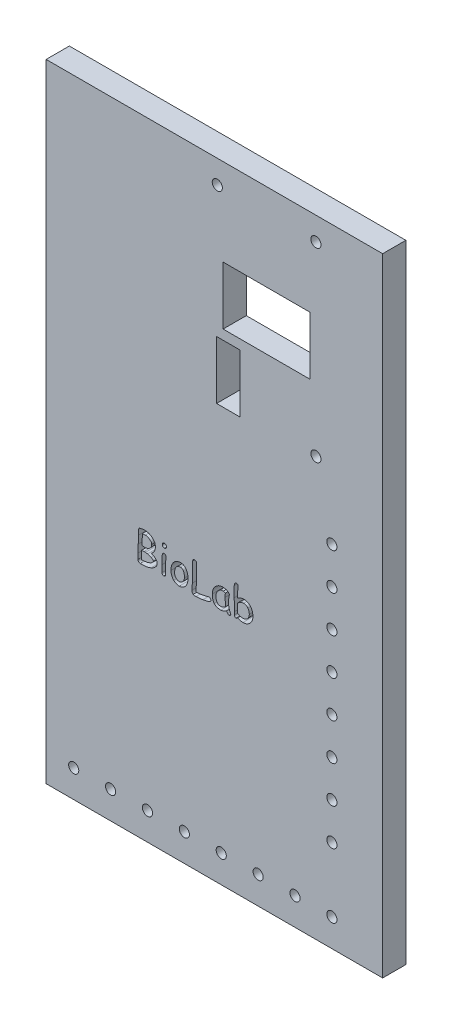
from build123d import *

# Parameters (mm, degrees)
ESBO_O1_W                = 116
ESBO_O1_H                = 216.23
ESBO_O1_R                = 1.75
ESBO_O1_W_2              = 8
ESBO_O1_H_2              = 20
ESBO_O1_W_3              = 30
RESSALTO_EXTRUS_O1_DEPTH = 8
ESBO_O2_R                = 1.75
CORTE_EXTRUS_O1_DEPTH    = 100
PADR_O_LINEAR1_COUNT     = 8
PADR_O_LINEAR1_PITCH     = 12.714285714
ESBO_O3_R                = 1.75
CORTE_EXTRUS_O2_DEPTH    = 100
PADR_O_LINEAR2_COUNT     = 8
PADR_O_LINEAR2_PITCH     = 12.714285714
CORTE_EXTRUS_O3_DEPTH    = 10


with BuildPart() as part:
    # Esboço1 → Ressalto-extrusão1 (new body)
    with BuildSketch(Plane.XY):
        Rectangle(ESBO_O1_W, ESBO_O1_H)
        with Locations((35, 100.115)):
            Circle(ESBO_O1_R, mode=Mode.SUBTRACT)
        with Locations((35, 36.115)):
            Circle(ESBO_O1_R, mode=Mode.SUBTRACT)
        with Locations((1, 100.115)):
            Circle(ESBO_O1_R, mode=Mode.SUBTRACT)
        with Locations((4.75, 44.775)):
            Rectangle(ESBO_O1_W_2, ESBO_O1_H_2, mode=Mode.SUBTRACT)
        with Locations((18, 68.115)):
            Rectangle(ESBO_O1_W_3, ESBO_O1_H_2, mode=Mode.SUBTRACT)
    extrude(amount=RESSALTO_EXTRUS_O1_DEPTH)

    # Esboço2 → Corte-extrusão1 (cut)
    with BuildSketch(Plane.XY.offset(8)):
        with Locations((-48.5, -98.615)):
            Circle(ESBO_O2_R)
    corte_extrus_o1 = extrude(amount=-CORTE_EXTRUS_O1_DEPTH, mode=Mode.SUBTRACT)

    # Padrão linear1: Corte-extrusão1 ×8
    with Locations(*[(i * PADR_O_LINEAR1_PITCH, 0, 0) for i in range(1, PADR_O_LINEAR1_COUNT)]):
        add(corte_extrus_o1, mode=Mode.SUBTRACT)

    # Esboço3 → Corte-extrusão2 (cut)
    with BuildSketch(Plane.XY.offset(8)):
        with Locations((40.5, 12.615)):
            Circle(ESBO_O3_R)
    corte_extrus_o2 = extrude(amount=-CORTE_EXTRUS_O2_DEPTH, mode=Mode.SUBTRACT)

    # Padrão linear2: Corte-extrusão2 ×8
    with Locations(*[(0, -i * PADR_O_LINEAR2_PITCH, 0) for i in range(1, PADR_O_LINEAR2_COUNT)]):
        add(corte_extrus_o2, mode=Mode.SUBTRACT)

    # Esboço4 → Corte-extrusão3 (cut)
    with BuildSketch(Plane.XY.offset(8)):
        with BuildLine():
            add(Edge.make_bspline(
                [(-21.819466883, -25.601114781), (-21.94523308, -25.648253776), (-22.202594077, -25.744716411), (-22.60800252, -25.862594403), (-23.038588398, -25.961611004), (-23.494895263, -26.043335334), (-23.976448386, -26.10769292), (-24.484176902, -26.151521549), (-25.016420425, -26.179378491), (-25.379977965, -26.18316585), (-25.565560633, -26.185099156)],
                knots=[0, 0, 0, 0, 0.000402818, 0.000824304, 0.001265386, 0.001727798, 0.002214506, 0.002722356, 0.00325626, 0.003812987, 0.003812987, 0.003812987, 0.003812987], degree=3))
            add(Edge.make_bspline(
                [(-25.565560633, -26.185099156), (-25.612223453, -26.181454862), (-25.706124052, -26.17412137), (-25.844171923, -26.120748716), (-25.977111363, -26.035523199), (-26.100323053, -25.919661015), (-26.206255294, -25.78799559), (-26.287415281, -25.64915079), (-26.337409386, -25.506155039), (-26.343711456, -25.408771054), (-26.346810633, -25.360880406)],
                knots=[0, 0, 0, 0, 0.000139782, 0.000281285, 0.000438424, 0.000611196, 0.000786281, 0.000943747, 0.001091979, 0.00123541, 0.00123541, 0.00123541, 0.00123541], degree=3))
            Line((-26.346810633, -25.360880406), (-26.346810633, -23.429239781))
            add(Edge.make_bspline(
                [(-26.346810633, -23.429239781), (-26.346277208, -23.345905207), (-26.34515614, -23.170765958), (-26.340942364, -22.895374692), (-26.335511528, -22.594563548), (-26.32573399, -22.268370863), (-26.310768736, -21.917554572), (-26.298387231, -21.541152007), (-26.280463804, -21.139460372), (-26.266246955, -20.862825102), (-26.258920008, -20.720255406)],
                knots=[0, 0, 0, 0, 0.000250008, 0.000525426, 0.000826264, 0.001152582, 0.001504411, 0.00187966, 0.002282387, 0.002710661, 0.002710661, 0.002710661, 0.002710661], degree=3))
            add(Edge.make_bspline(
                [(-26.258920008, -20.720255406), (-26.250912852, -20.567270159), (-26.235513639, -20.273051778), (-26.216387988, -19.847868517), (-26.198901421, -19.455288101), (-26.182529154, -19.09531503), (-26.171535388, -18.76778713), (-26.160854644, -18.473559092), (-26.15543455, -18.211802853), (-26.152749609, -18.048381002), (-26.151498133, -17.972208531)],
                knots=[0, 0, 0, 0, 0.000459582, 0.00088386, 0.001276832, 0.001638498, 0.00196488, 0.002259963, 0.002521748, 0.002750297, 0.002750297, 0.002750297, 0.002750297], degree=3))
            add(Edge.make_bspline(
                [(-26.151498133, -17.972208531), (-26.151619343, -17.918171638), (-26.151876375, -17.803583883), (-26.149699458, -17.622585839), (-26.145737236, -17.422712056), (-26.139842972, -17.20460874), (-26.131933609, -16.967629118), (-26.122168842, -16.712417831), (-26.110400076, -16.438328656), (-26.101443649, -16.249548804), (-26.096810633, -16.151896031)],
                knots=[0, 0, 0, 0, 0.000162109, 0.000343761, 0.000543018, 0.000761846, 0.000998303, 0.001254349, 0.001528037, 0.001821325, 0.001821325, 0.001821325, 0.001821325], degree=3))
            add(Edge.make_bspline(
                [(-26.096810633, -16.151896031), (-26.088148285, -16.100639541), (-26.072151648, -16.005984904), (-26.024696772, -15.880454097), (-25.963933289, -15.778816238), (-25.905630012, -15.73507811), (-25.878060633, -15.714396031)],
                knots=[0, 0, 0, 0, 0.000155516, 0.000287189, 0.000401493, 0.000504027, 0.000504027, 0.000504027, 0.000504027], degree=3))
            add(Edge.make_bspline(
                [(-25.878060633, -15.714396031), (-25.723141407, -15.670427215), (-25.406647136, -15.580600544), (-24.906991612, -15.499350974), (-24.378666074, -15.444149988), (-24.015588878, -15.438169009), (-23.829232508, -15.435099156)],
                knots=[0, 0, 0, 0, 0.000482742, 0.000986224, 0.001516198, 0.002075068, 0.002075068, 0.002075068, 0.002075068], degree=3))
            add(Edge.make_bspline(
                [(-23.829232508, -15.435099156), (-23.732104914, -15.43718088), (-23.538434591, -15.441331793), (-23.249605599, -15.480271356), (-22.963892598, -15.542241596), (-22.681656588, -15.631747251), (-22.401503192, -15.74248175), (-22.125314536, -15.880965841), (-21.850915073, -16.04224301), (-21.675945253, -16.168051993), (-21.587045008, -16.231974156)],
                knots=[0, 0, 0, 0, 0.000291251, 0.000580749, 0.000872674, 0.001167337, 0.001468005, 0.001775465, 0.002093345, 0.002421679, 0.002421679, 0.002421679, 0.002421679], degree=3))
            add(Edge.make_bspline(
                [(-21.587045008, -16.231974156), (-21.488456053, -16.308879509), (-21.296885953, -16.458315783), (-21.042479205, -16.708319617), (-20.828540263, -16.972690516), (-20.652284433, -17.250975374), (-20.514063882, -17.542476142), (-20.41887628, -17.849040362), (-20.357445397, -18.167670528), (-20.350387537, -18.38533452), (-20.346810633, -18.495646031)],
                knots=[0, 0, 0, 0, 0.000374888, 0.000728452, 0.001067341, 0.001393003, 0.001714534, 0.002032036, 0.002353822, 0.002684477, 0.002684477, 0.002684477, 0.002684477], degree=3))
            add(Edge.make_bspline(
                [(-20.346810633, -18.495646031), (-20.350725081, -18.634581038), (-20.358377914, -18.906202147), (-20.424450427, -19.301605152), (-20.531827884, -19.674341074), (-20.683603517, -20.02469636), (-20.877347595, -20.353125292), (-21.117595128, -20.655855526), (-21.397961008, -20.938249357), (-21.612293688, -21.101621413), (-21.721810633, -21.185099156)],
                knots=[0, 0, 0, 0, 0.00041657, 0.000814404, 0.001198857, 0.001577648, 0.001956826, 0.002339344, 0.002734329, 0.003147031, 0.003147031, 0.003147031, 0.003147031], degree=3))
            add(Edge.make_bspline(
                [(-21.721810633, -21.185099156), (-21.6408021, -21.220294226), (-21.482072077, -21.289256273), (-21.254835512, -21.40032838), (-21.042556554, -21.513450297), (-20.847446356, -21.630824639), (-20.66740903, -21.74984009), (-20.502347488, -21.870796692), (-20.353368003, -21.995855752), (-20.220517196, -22.124750647), (-20.102974662, -22.255849298), (-19.999754426, -22.388471284), (-19.915862215, -22.526935302), (-19.845039181, -22.667016236), (-19.789961262, -22.810312364), (-19.750511196, -22.956186147), (-19.726220742, -23.105506272), (-19.72328799, -23.206493216), (-19.721810633, -23.257364781)],
                knots=[0, 0, 0, 0, 0.000264942, 0.000519134, 0.000758565, 0.000986336, 0.001201933, 0.001405845, 0.001599904, 0.001784988, 0.00196065, 0.002127844, 0.002288298, 0.002445522, 0.002598228, 0.002747945, 0.002898221, 0.003050765, 0.003050765, 0.003050765, 0.003050765], degree=3))
            add(Edge.make_bspline(
                [(-19.721810633, -23.257364781), (-19.724673762, -23.323939655), (-19.730447694, -23.45819793), (-19.770437993, -23.658122105), (-19.838412323, -23.855887914), (-19.932820619, -24.051877942), (-20.055326576, -24.245398508), (-20.203482076, -24.437772116), (-20.376620664, -24.629223947), (-20.507856448, -24.748683593), (-20.575326258, -24.810099156)],
                knots=[0, 0, 0, 0, 0.000199687, 0.0004027, 0.000608993, 0.00082564, 0.001053788, 0.001294815, 0.001553374, 0.00182695, 0.00182695, 0.00182695, 0.00182695], degree=3))
            add(Edge.make_bspline(
                [(-20.575326258, -24.810099156), (-20.673454846, -24.894682717), (-20.866592346, -25.061160784), (-21.176871327, -25.274137089), (-21.49103632, -25.460170931), (-21.710925138, -25.554534793), (-21.819466883, -25.601114781)],
                knots=[0, 0, 0, 0, 0.000388363, 0.000764378, 0.001127523, 0.001481519, 0.001481519, 0.001481519, 0.001481519], degree=3))
        make_face()
        with BuildLine():
            add(Edge.make_bspline(
                [(-23.811654383, -16.810099156), (-23.924954262, -16.809928554), (-24.134026775, -16.809613744), (-24.41980829, -16.820666477), (-24.652006167, -16.831503773), (-24.787621319, -16.847875556), (-24.846810633, -16.855021031)],
                knots=[0, 0, 0, 0, 0.000339849, 0.000627125, 0.000857999, 0.001036803, 0.001036803, 0.001036803, 0.001036803], degree=3))
            Line((-24.846810633, -16.855021031), (-24.858529383, -17.970255406))
            Line((-24.858529383, -17.970255406), (-24.971810633, -20.435099156))
            add(Edge.make_bspline(
                [(-24.971810633, -20.435099156), (-24.896968446, -20.445722248), (-24.756485318, -20.465662409), (-24.559066964, -20.490566001), (-24.389789207, -20.512024644), (-24.247901789, -20.529829477), (-24.13395884, -20.54370593), (-24.047985443, -20.552514379), (-23.990179159, -20.560863775), (-23.960753025, -20.560299204), (-23.950326258, -20.560099156)],
                knots=[0, 0, 0, 0, 0.000226773, 0.000425666, 0.000596941, 0.00073866, 0.000854702, 0.000941193, 0.000998136, 0.001029386, 0.001029386, 0.001029386, 0.001029386], degree=3))
            add(Edge.make_bspline(
                [(-23.950326258, -20.560099156), (-23.867541256, -20.551848654), (-23.705293532, -20.535678756), (-23.468100585, -20.497202632), (-23.242102048, -20.442473475), (-23.028516562, -20.371799134), (-22.825020698, -20.290577614), (-22.635323388, -20.191233035), (-22.454741234, -20.081797896), (-22.344714984, -19.995472616), (-22.290170008, -19.952677281)],
                knots=[0, 0, 0, 0, 0.000249549, 0.000489084, 0.000720255, 0.000946312, 0.001163566, 0.001376707, 0.001588087, 0.0017959, 0.0017959, 0.0017959, 0.0017959], degree=3))
            add(Edge.make_bspline(
                [(-22.290170008, -19.952677281), (-22.234939085, -19.904422226), (-22.126153273, -19.809376461), (-21.985786602, -19.647694067), (-21.865429151, -19.477160094), (-21.767114314, -19.29624093), (-21.690209941, -19.104951016), (-21.635284833, -18.903171346), (-21.604305161, -18.690611527), (-21.599338448, -18.54587326), (-21.596810633, -18.472208531)],
                knots=[0, 0, 0, 0, 0.000219803, 0.000432935, 0.000640463, 0.000844973, 0.001049166, 0.001257638, 0.001470878, 0.001691892, 0.001691892, 0.001691892, 0.001691892], degree=3))
            add(Edge.make_bspline(
                [(-21.596810633, -18.472208531), (-21.599209508, -18.421245735), (-21.604026389, -18.318913729), (-21.638823404, -18.167744614), (-21.693450164, -18.019343415), (-21.773829554, -17.876056557), (-21.874192619, -17.734265223), (-21.997913673, -17.596047403), (-22.143949365, -17.46125083), (-22.307548074, -17.330377136), (-22.483826898, -17.209602178), (-22.666278113, -17.10376034), (-22.850302639, -17.013647728), (-23.036477546, -16.938143216), (-23.22702513, -16.881728562), (-23.419732252, -16.841274277), (-23.614913549, -16.813943508), (-23.745807168, -16.811385823), (-23.811654383, -16.810099156)],
                knots=[0, 0, 0, 0, 0.000152794, 0.000306806, 0.000463166, 0.000625745, 0.000798075, 0.000983467, 0.001181081, 0.001393684, 0.001611464, 0.001821505, 0.002025903, 0.002225743, 0.002423482, 0.002621143, 0.002816163, 0.003013583, 0.003013583, 0.003013583, 0.003013583], degree=3))
        make_face(mode=Mode.SUBTRACT)
        with BuildLine():
            Line((-23.061654383, -22.030802281), (-23.764779383, -21.915567906))
            add(Edge.make_bspline(
                [(-23.764779383, -21.915567906), (-23.800594863, -21.915981185), (-23.887911786, -21.916988746), (-24.026498025, -21.925330719), (-24.167034532, -21.933805421), (-24.256306813, -21.934714529), (-24.294076258, -21.935099156)],
                knots=[0, 0, 0, 0, 0.00010744, 0.000261934, 0.000416429, 0.000529727, 0.000529727, 0.000529727, 0.000529727], degree=3))
            add(Edge.make_bspline(
                [(-24.294076258, -21.935099156), (-24.417774175, -21.935099156), (-24.672331467, -21.935099156), (-24.926888758, -21.935099156), (-25.057748133, -21.935099156)],
                knots=[0, 0, 0, 0, 0.000371094, 0.000763672, 0.000763672, 0.000763672, 0.000763672], degree=3))
            add(Edge.make_bspline(
                [(-25.057748133, -21.935099156), (-25.064029786, -22.071151319), (-25.076229682, -22.335384712), (-25.08704956, -22.720870337), (-25.096108828, -23.084145027), (-25.096581516, -23.319208304), (-25.096810633, -23.433146031)],
                knots=[0, 0, 0, 0, 0.000408581, 0.000793525, 0.001156891, 0.001498693, 0.001498693, 0.001498693, 0.001498693], degree=3))
            Line((-25.096810633, -23.433146031), (-25.096810633, -24.810099156))
            add(Edge.make_bspline(
                [(-25.096810633, -24.810099156), (-24.955479246, -24.803870377), (-24.679049017, -24.791687502), (-24.274539111, -24.758119157), (-23.889461455, -24.713715026), (-23.524598055, -24.657193759), (-23.179945886, -24.5903273), (-22.856924966, -24.506137344), (-22.551537716, -24.417739825), (-22.35870673, -24.342729965), (-22.264779383, -24.306192906)],
                knots=[0, 0, 0, 0, 0.000424372, 0.00083003, 0.001217409, 0.00158701, 0.001937491, 0.002270033, 0.002588248, 0.002890453, 0.002890453, 0.002890453, 0.002890453], degree=3))
            add(Edge.make_bspline(
                [(-22.264779383, -24.306192906), (-22.187083193, -24.273443071), (-22.029445715, -24.206997067), (-21.80590188, -24.072853047), (-21.584126337, -23.918829395), (-21.446586622, -23.797865576), (-21.376107508, -23.735880406)],
                knots=[0, 0, 0, 0, 0.000252649, 0.000512598, 0.00078029, 0.001061628, 0.001061628, 0.001061628, 0.001061628], degree=3))
            add(Edge.make_bspline(
                [(-21.376107508, -23.735880406), (-21.315441067, -23.681797064), (-21.207477004, -23.585548508), (-21.081800197, -23.441619534), (-20.993748783, -23.321915264), (-20.978278824, -23.24058766), (-20.971810633, -23.206583531)],
                knots=[0, 0, 0, 0, 0.000243209, 0.000432823, 0.000575882, 0.000678677, 0.000678677, 0.000678677, 0.000678677], degree=3))
            add(Edge.make_bspline(
                [(-20.971810633, -23.206583531), (-20.974846601, -23.178841187), (-20.981263942, -23.120200232), (-21.024636576, -23.0339733), (-21.093065931, -22.947527479), (-21.18918591, -22.860622026), (-21.308746673, -22.768300884), (-21.456054954, -22.675879047), (-21.62904318, -22.579849271), (-21.75469719, -22.518472), (-21.821420008, -22.485880406)],
                knots=[0, 0, 0, 0, 8.3163e-05, 0.000175787, 0.000284392, 0.000412898, 0.000563301, 0.000737217, 0.000933941, 0.001156674, 0.001156674, 0.001156674, 0.001156674], degree=3))
            add(Edge.make_bspline(
                [(-21.821420008, -22.485880406), (-21.92648771, -22.43743689), (-22.133452151, -22.342011893), (-22.445277046, -22.217146487), (-22.753457942, -22.111820488), (-22.959738223, -22.057593844), (-23.061654383, -22.030802281)],
                knots=[0, 0, 0, 0, 0.000347047, 0.00068362, 0.001007261, 0.001323312, 0.001323312, 0.001323312, 0.001323312], degree=3))
        make_face(mode=Mode.SUBTRACT)
        with BuildLine():
            add(Edge.make_bspline(
                [(-17.217904383, -17.435099156), (-17.267712112, -17.432674938), (-17.365213437, -17.427929401), (-17.505802286, -17.384027374), (-17.636370279, -17.315381902), (-17.751860405, -17.219340103), (-17.850944719, -17.10591059), (-17.918064777, -16.974471672), (-17.965497674, -16.834148367), (-17.969669935, -16.735641132), (-17.971810633, -16.685099156)],
                knots=[0, 0, 0, 0, 0.000149066, 0.000291804, 0.000437715, 0.000589016, 0.000740064, 0.000885975, 0.001029287, 0.001180298, 0.001180298, 0.001180298, 0.001180298], degree=3))
            add(Edge.make_bspline(
                [(-17.971810633, -16.685099156), (-17.96964099, -16.634573274), (-17.965412315, -16.536097407), (-17.918572421, -16.39609665), (-17.850267205, -16.265989164), (-17.752022581, -16.152611198), (-17.635791919, -16.057174566), (-17.506383601, -15.985743546), (-17.365139592, -15.942404093), (-17.267687144, -15.937569081), (-17.217904383, -15.935099156)],
                knots=[0, 0, 0, 0, 0.000151011, 0.000294323, 0.000438511, 0.000589559, 0.00074086, 0.000887696, 0.001030434, 0.0011795, 0.0011795, 0.0011795, 0.0011795], degree=3))
            add(Edge.make_bspline(
                [(-17.217904383, -15.935099156), (-17.168150462, -15.937621577), (-17.07075447, -15.942559352), (-16.930200484, -15.984814349), (-16.803666231, -16.05798919), (-16.689177024, -16.152430231), (-16.59405944, -16.26725691), (-16.522021806, -16.395069007), (-16.478990417, -16.536578427), (-16.474248408, -16.634671452), (-16.471810633, -16.685099156)],
                knots=[0, 0, 0, 0, 0.000149066, 0.000291804, 0.000435223, 0.000585016, 0.00073481, 0.000879933, 0.001022672, 0.001173683, 0.001173683, 0.001173683, 0.001173683], degree=3))
            add(Edge.make_bspline(
                [(-16.471810633, -16.685099156), (-16.474218757, -16.735543664), (-16.47890309, -16.833669377), (-16.522520625, -16.975493606), (-16.593388379, -17.10464738), (-16.689343068, -17.21951847), (-16.803073813, -17.314560484), (-16.930800585, -17.384953992), (-17.070677058, -17.427776322), (-17.168124288, -17.43262318), (-17.217904383, -17.435099156)],
                knots=[0, 0, 0, 0, 0.000151011, 0.000293749, 0.000440585, 0.000590378, 0.000740172, 0.000882643, 0.001025381, 0.001174447, 0.001174447, 0.001174447, 0.001174447], degree=3))
        make_face()
        with BuildLine():
            add(Edge.make_bspline(
                [(-16.846810633, -22.798380406), (-16.846810633, -22.871948114), (-16.846810633, -23.036010614), (-16.846810633, -23.306192906), (-16.846810633, -23.625854364), (-16.846810633, -23.977416864), (-16.846810633, -24.328979364), (-16.846810633, -24.647338739), (-16.846810633, -24.916869989), (-16.846810633, -25.080281447), (-16.846810633, -25.153849156)],
                knots=[0, 0, 0, 0, 0.000220703, 0.000492188, 0.000810547, 0.001179687, 0.001546875, 0.001865234, 0.002134766, 0.002355469, 0.002355469, 0.002355469, 0.002355469], degree=3))
            add(Edge.make_bspline(
                [(-16.846810633, -25.153849156), (-16.848017246, -25.200369976), (-16.85033007, -25.289540656), (-16.886896264, -25.415720182), (-16.937540256, -25.531420633), (-17.015921664, -25.628197548), (-17.107281318, -25.710984754), (-17.217452426, -25.766831126), (-17.339814041, -25.804515482), (-17.426579654, -25.808185811), (-17.471810633, -25.810099156)],
                knots=[0, 0, 0, 0, 0.000139015, 0.000266463, 0.000391417, 0.000515268, 0.000637084, 0.000758524, 0.000882743, 0.001018017, 0.001018017, 0.001018017, 0.001018017], degree=3))
            add(Edge.make_bspline(
                [(-17.471810633, -25.810099156), (-17.515737658, -25.808144338), (-17.600570682, -25.804369143), (-17.720923366, -25.766502364), (-17.830568654, -25.710401184), (-17.923932526, -25.6289853), (-18.001649805, -25.530828169), (-18.055413206, -25.416297654), (-18.090710044, -25.289371909), (-18.094718379, -25.200327957), (-18.096810633, -25.153849156)],
                knots=[0, 0, 0, 0, 0.000131383, 0.00025373, 0.00037517, 0.000498465, 0.000622315, 0.000748106, 0.000875554, 0.00101472, 0.00101472, 0.00101472, 0.00101472], degree=3))
            add(Edge.make_bspline(
                [(-18.096810633, -25.153849156), (-18.096810633, -25.080281447), (-18.096810633, -24.916869989), (-18.096810633, -24.647338739), (-18.096810633, -24.328979364), (-18.096810633, -23.977416864), (-18.096810633, -23.625854364), (-18.096810633, -23.306192906), (-18.096810633, -23.036010614), (-18.096810633, -22.871948114), (-18.096810633, -22.798380406)],
                knots=[0, 0, 0, 0, 0.000220703, 0.000490234, 0.000808594, 0.001175781, 0.001544922, 0.001863281, 0.002134766, 0.002355469, 0.002355469, 0.002355469, 0.002355469], degree=3))
            add(Edge.make_bspline(
                [(-18.096810633, -22.798380406), (-18.095970698, -22.689647565), (-18.09418982, -22.459106066), (-18.081486238, -22.093830327), (-18.062147661, -21.690134517), (-18.034310687, -21.261271031), (-18.006473398, -20.832407543), (-17.987135661, -20.428711738), (-17.974406805, -20.06278532), (-17.972644453, -19.831592516), (-17.971810633, -19.722208531)],
                knots=[0, 0, 0, 0, 0.000326195, 0.000691618, 0.001096386, 0.001538638, 0.001980891, 0.002385659, 0.002751081, 0.00307923, 0.00307923, 0.00307923, 0.00307923], degree=3))
            add(Edge.make_bspline(
                [(-17.971810633, -19.722208531), (-17.969575426, -19.67513453), (-17.965261654, -19.58428548), (-17.931807265, -19.455295661), (-17.875349048, -19.34086634), (-17.799824778, -19.241068192), (-17.704864861, -19.160422953), (-17.596888143, -19.100715136), (-17.475110949, -19.066622603), (-17.39064306, -19.062327821), (-17.346810633, -19.060099156)],
                knots=[0, 0, 0, 0, 0.000141112, 0.000272336, 0.000396371, 0.000521767, 0.000645061, 0.000767424, 0.000889225, 0.001020608, 0.001020608, 0.001020608, 0.001020608], degree=3))
            add(Edge.make_bspline(
                [(-17.346810633, -19.060099156), (-17.303017183, -19.062438), (-17.217997651, -19.066978574), (-17.095653965, -19.099772482), (-16.988527482, -19.161127421), (-16.89355443, -19.240894072), (-16.818860721, -19.341460115), (-16.758793156, -19.45440875), (-16.729186743, -19.584700138), (-16.724331075, -19.675221443), (-16.721810633, -19.722208531)],
                knots=[0, 0, 0, 0, 0.000131383, 0.000255064, 0.000375716, 0.00049901, 0.000624406, 0.000749315, 0.000880058, 0.00102117, 0.00102117, 0.00102117, 0.00102117], degree=3))
            add(Edge.make_bspline(
                [(-16.721810633, -19.722208531), (-16.722644453, -19.831592516), (-16.724406805, -20.06278532), (-16.737135661, -20.428711738), (-16.756473398, -20.832407543), (-16.784310687, -21.261271031), (-16.812147661, -21.690134517), (-16.831486238, -22.093830327), (-16.84418982, -22.459106066), (-16.845970698, -22.689647565), (-16.846810633, -22.798380406)],
                knots=[0, 0, 0, 0, 0.000328148, 0.000693571, 0.001098339, 0.001540591, 0.001982844, 0.002387612, 0.002753034, 0.00307923, 0.00307923, 0.00307923, 0.00307923], degree=3))
        make_face()
        with BuildLine():
            add(Edge.make_bspline(
                [(-12.114388758, -26.185099156), (-12.205645223, -26.182185319), (-12.38565537, -26.17643756), (-12.651064302, -26.139411844), (-12.906129924, -26.074264369), (-13.151728412, -25.98421135), (-13.387496713, -25.867468708), (-13.615034733, -25.727215585), (-13.830463633, -25.557982502), (-13.963132983, -25.429788688), (-14.030404383, -25.364786656)],
                knots=[0, 0, 0, 0, 0.000273779, 0.00054005, 0.000802009, 0.001062156, 0.001323327, 0.001589984, 0.001862696, 0.002143219, 0.002143219, 0.002143219, 0.002143219], degree=3))
            add(Edge.make_bspline(
                [(-14.030404383, -25.364786656), (-14.102536326, -25.286876542), (-14.246407892, -25.131480062), (-14.429828156, -24.870965434), (-14.586836886, -24.591904734), (-14.717824814, -24.293450941), (-14.823787214, -23.975877584), (-14.901322551, -23.638389789), (-14.952470025, -23.2815673), (-14.96526637, -23.036826276), (-14.971810633, -22.911661656)],
                knots=[0, 0, 0, 0, 0.000318234, 0.000634736, 0.000953066, 0.001277502, 0.001611023, 0.001955926, 0.002315003, 0.002690862, 0.002690862, 0.002690862, 0.002690862], degree=3))
            add(Edge.make_bspline(
                [(-14.971810633, -22.911661656), (-14.9723729, -22.788555897), (-14.973481378, -22.545859443), (-14.942930851, -22.187463129), (-14.889440207, -21.840374494), (-14.806254428, -21.504957063), (-14.699100117, -21.180165868), (-14.565879337, -20.866279556), (-14.405928748, -20.564129744), (-14.279445065, -20.374194929), (-14.215951258, -20.278849156)],
                knots=[0, 0, 0, 0, 0.000369161, 0.000727782, 0.001077784, 0.001421695, 0.001763246, 0.002102798, 0.002443561, 0.00278705, 0.00278705, 0.00278705, 0.00278705], degree=3))
            add(Edge.make_bspline(
                [(-14.215951258, -20.278849156), (-14.136921989, -20.172108365), (-13.982215869, -19.963154726), (-13.71427169, -19.687673742), (-13.422798977, -19.454904856), (-13.108626424, -19.263861603), (-12.770756898, -19.116345796), (-12.41067674, -19.010559673), (-12.027420336, -18.947313218), (-11.764368128, -18.93922846), (-11.630013758, -18.935099156)],
                knots=[0, 0, 0, 0, 0.000398102, 0.000779317, 0.00114901, 0.001514453, 0.001879149, 0.002251808, 0.002637761, 0.003040678, 0.003040678, 0.003040678, 0.003040678], degree=3))
            add(Edge.make_bspline(
                [(-11.630013758, -18.935099156), (-11.522318389, -18.938743392), (-11.31252799, -18.945842357), (-11.008427391, -19.004297157), (-10.723749987, -19.097592121), (-10.460108158, -19.231910415), (-10.216513552, -19.404112239), (-9.995389433, -19.61592354), (-9.791904455, -19.863495667), (-9.678540671, -20.050088944), (-9.620248133, -20.146036656)],
                knots=[0, 0, 0, 0, 0.000322857, 0.000628925, 0.000925388, 0.001218877, 0.001513132, 0.00181708, 0.002134936, 0.002471384, 0.002471384, 0.002471384, 0.002471384], degree=3))
            add(Edge.make_bspline(
                [(-9.620248133, -20.146036656), (-9.576566563, -20.22871415), (-9.488413617, -20.395564029), (-9.380249096, -20.660134364), (-9.288657059, -20.937028018), (-9.210969819, -21.22538525), (-9.158475543, -21.527667285), (-9.118618372, -21.84106357), (-9.096935575, -22.167207308), (-9.096852739, -22.388846417), (-9.096810633, -22.501505406)],
                knots=[0, 0, 0, 0, 0.000280387, 0.000565844, 0.000856132, 0.001155062, 0.001460774, 0.001775706, 0.002102585, 0.002440498, 0.002440498, 0.002440498, 0.002440498], degree=3))
            add(Edge.make_bspline(
                [(-9.096810633, -22.501505406), (-9.100326913, -22.621396293), (-9.107262985, -22.857888243), (-9.146657787, -23.2052782), (-9.210108202, -23.53909568), (-9.292279861, -23.860700192), (-9.403646051, -24.167058343), (-9.531997736, -24.462760932), (-9.685590949, -24.744001015), (-9.806234572, -24.919785218), (-9.866341883, -25.007364781)],
                knots=[0, 0, 0, 0, 0.000359715, 0.000709558, 0.001047421, 0.00137856, 0.001704124, 0.002024198, 0.002344992, 0.002663513, 0.002663513, 0.002663513, 0.002663513], degree=3))
            add(Edge.make_bspline(
                [(-9.866341883, -25.007364781), (-9.937934993, -25.100829809), (-10.078169218, -25.283906028), (-10.317497776, -25.524575148), (-10.574202922, -25.728981206), (-10.848587635, -25.895471635), (-11.140398199, -26.026308013), (-11.449925683, -26.11708002), (-11.77616044, -26.176663007), (-12.000186741, -26.18225071), (-12.114388758, -26.185099156)],
                knots=[0, 0, 0, 0, 0.000352916, 0.000691281, 0.001015223, 0.001335112, 0.001651615, 0.001971701, 0.00230083, 0.002643079, 0.002643079, 0.002643079, 0.002643079], degree=3))
        make_face()
        with BuildLine():
            add(Edge.make_bspline(
                [(-11.749154383, -20.310099156), (-11.829400413, -20.312651202), (-11.986431516, -20.317645227), (-12.214774194, -20.358911709), (-12.429011867, -20.430274907), (-12.629794257, -20.530571282), (-12.817097992, -20.661025904), (-12.989059511, -20.821195436), (-13.14958298, -21.007907086), (-13.239800384, -21.149358724), (-13.286263758, -21.222208531)],
                knots=[0, 0, 0, 0, 0.000240623, 0.000470868, 0.000693216, 0.000915949, 0.001141879, 0.00137548, 0.001619316, 0.00187825, 0.00187825, 0.00187825, 0.00187825], degree=3))
            add(Edge.make_bspline(
                [(-13.286263758, -21.222208531), (-13.320850106, -21.28431854), (-13.390018448, -21.408530744), (-13.480763243, -21.602230604), (-13.553962623, -21.803373745), (-13.615033647, -22.010847456), (-13.664384602, -22.223913579), (-13.696201314, -22.444805924), (-13.719640387, -22.670922966), (-13.721082082, -22.824358418), (-13.721810633, -22.901896031)],
                knots=[0, 0, 0, 0, 0.00021324, 0.000426453, 0.000640879, 0.000854708, 0.001075031, 0.001296286, 0.001523865, 0.001756361, 0.001756361, 0.001756361, 0.001756361], degree=3))
            add(Edge.make_bspline(
                [(-13.721810633, -22.901896031), (-13.720600641, -22.978803904), (-13.718245312, -23.128509978), (-13.691638396, -23.345916054), (-13.651953347, -23.55029674), (-13.592469496, -23.741003813), (-13.518083882, -23.919596843), (-13.429064244, -24.086431412), (-13.320372348, -24.23915249), (-13.235276756, -24.329267087), (-13.192513758, -24.374552281)],
                knots=[0, 0, 0, 0, 0.000230601, 0.00044888, 0.000656104, 0.000854412, 0.00104702, 0.001235787, 0.001420603, 0.001607297, 0.001607297, 0.001607297, 0.001607297], degree=3))
            add(Edge.make_bspline(
                [(-13.192513758, -24.374552281), (-13.155237202, -24.408954621), (-13.081781432, -24.476746568), (-12.964780128, -24.5675845), (-12.840557186, -24.642296193), (-12.711032686, -24.702085743), (-12.578471191, -24.752602866), (-12.439716831, -24.784419168), (-12.297480879, -24.807903572), (-12.200427589, -24.809363256), (-12.151498133, -24.810099156)],
                knots=[0, 0, 0, 0, 0.000152143, 0.000299808, 0.000443505, 0.000585923, 0.000727427, 0.000868119, 0.001012307, 0.001158909, 0.001158909, 0.001158909, 0.001158909], degree=3))
            add(Edge.make_bspline(
                [(-12.151498133, -24.810099156), (-12.094122518, -24.808672145), (-11.981480304, -24.805870578), (-11.815308378, -24.781447384), (-11.655929486, -24.742423655), (-11.500877811, -24.689702608), (-11.353652292, -24.618857095), (-11.210847746, -24.534526226), (-11.076368061, -24.432361464), (-10.992679329, -24.35507271), (-10.950326258, -24.315958531)],
                knots=[0, 0, 0, 0, 0.000172052, 0.000337781, 0.000502632, 0.000663844, 0.000828093, 0.000991888, 0.001160638, 0.001333542, 0.001333542, 0.001333542, 0.001333542], degree=3))
            add(Edge.make_bspline(
                [(-10.950326258, -24.315958531), (-10.904322172, -24.269404404), (-10.812885189, -24.176874167), (-10.694905558, -24.020717712), (-10.596020189, -23.852063021), (-10.510971874, -23.672595572), (-10.44195413, -23.481294078), (-10.394593746, -23.276541489), (-10.360493623, -23.061103538), (-10.351438489, -22.913089327), (-10.346810633, -22.837442906)],
                knots=[0, 0, 0, 0, 0.000196189, 0.000389943, 0.000585226, 0.000781804, 0.000985051, 0.001193962, 0.001411357, 0.0016386, 0.0016386, 0.0016386, 0.0016386], degree=3))
            add(Edge.make_bspline(
                [(-10.346810633, -22.837442906), (-10.343833687, -22.735886639), (-10.338051021, -22.538615396), (-10.346470344, -22.252483009), (-10.3655691, -21.985898396), (-10.395708904, -21.739093752), (-10.440739682, -21.51207859), (-10.496994514, -21.304338087), (-10.564538769, -21.115355431), (-10.646823526, -20.94658089), (-10.740798556, -20.797032474), (-10.845957226, -20.665807864), (-10.967490966, -20.557959973), (-11.099140991, -20.46636439), (-11.244135841, -20.395919272), (-11.40231089, -20.347299295), (-11.571393458, -20.314819757), (-11.689101931, -20.311693902), (-11.749154383, -20.310099156)],
                knots=[0, 0, 0, 0, 0.000304744, 0.000591959, 0.000858302, 0.001106372, 0.001337345, 0.001551984, 0.001751557, 0.001938486, 0.00211405, 0.002280605, 0.002441023, 0.002599756, 0.002760483, 0.002922321, 0.003095093, 0.003275045, 0.003275045, 0.003275045, 0.003275045], degree=3))
        make_face(mode=Mode.SUBTRACT)
        with BuildLine():
            add(Edge.make_bspline(
                [(-1.643685633, -25.560099156), (-1.709744293, -25.589607192), (-1.8486075, -25.651636616), (-2.075430873, -25.731632753), (-2.326738089, -25.814854676), (-2.606263951, -25.891294083), (-2.911584558, -25.967877), (-3.24323462, -26.041324961), (-3.601299831, -26.113992862), (-3.849316429, -26.158275664), (-3.977670008, -26.181192906)],
                knots=[0, 0, 0, 0, 0.000216964, 0.000456084, 0.000721055, 0.001011073, 0.001325137, 0.001665363, 0.002030017, 0.002421154, 0.002421154, 0.002421154, 0.002421154], degree=3))
            add(Edge.make_bspline(
                [(-3.977670008, -26.181192906), (-4.097439956, -26.200851173), (-4.330967249, -26.239180839), (-4.672433981, -26.293051604), (-4.996859197, -26.335721529), (-5.304302246, -26.370380093), (-5.595113615, -26.401266745), (-5.869417662, -26.419882254), (-6.12663656, -26.432688331), (-6.292108826, -26.43431285), (-6.372201258, -26.435099156)],
                knots=[0, 0, 0, 0, 0.00036412, 0.000709961, 0.001037015, 0.001345664, 0.001638151, 0.001914233, 0.002170361, 0.002410627, 0.002410627, 0.002410627, 0.002410627], degree=3))
            add(Edge.make_bspline(
                [(-6.372201258, -26.435099156), (-6.475214892, -26.432501055), (-6.667026853, -26.427663377), (-6.931486706, -26.392614198), (-7.152229313, -26.332411495), (-7.272287495, -26.263526494), (-7.327279383, -26.231974156)],
                knots=[0, 0, 0, 0, 0.000308896, 0.000575167, 0.00079947, 0.000989044, 0.000989044, 0.000989044, 0.000989044], degree=3))
            add(Edge.make_bspline(
                [(-7.327279383, -26.231974156), (-7.358824885, -26.207602576), (-7.422585365, -26.158342191), (-7.501935564, -26.064402444), (-7.571563292, -25.958674892), (-7.624858793, -25.837175271), (-7.672024608, -25.704046852), (-7.698079335, -25.554309051), (-7.719705972, -25.391454187), (-7.721089411, -25.277637758), (-7.721810633, -25.218302281)],
                knots=[0, 0, 0, 0, 0.000119285, 0.000241101, 0.000366786, 0.000497878, 0.000638082, 0.000789383, 0.000952665, 0.001130495, 0.001130495, 0.001130495, 0.001130495], degree=3))
            Line((-7.721810633, -25.218302281), (-7.612435633, -23.042521031))
            add(Edge.make_bspline(
                [(-7.612435633, -23.042521031), (-7.601086738, -22.78797591), (-7.578101547, -22.272439555), (-7.548423694, -21.488598715), (-7.525750567, -20.684501236), (-7.506011088, -19.859625903), (-7.4906831, -19.014558169), (-7.478340695, -18.148673782), (-7.473055212, -17.262580009), (-7.472228492, -16.664917243), (-7.471810633, -16.362833531)],
                knots=[0, 0, 0, 0, 0.000764393, 0.001548144, 0.002353173, 0.003177623, 0.004023471, 0.004888784, 0.005775522, 0.006681775, 0.006681775, 0.006681775, 0.006681775], degree=3))
            add(Edge.make_bspline(
                [(-7.471810633, -16.362833531), (-7.46987785, -16.316979939), (-7.466108458, -16.227554387), (-7.426944101, -16.099094286), (-7.363495454, -15.982429994), (-7.277330512, -15.879606064), (-7.174153659, -15.792821645), (-7.055735817, -15.730010652), (-6.925425761, -15.6907877), (-6.83472182, -15.687027204), (-6.788216883, -15.685099156)],
                knots=[0, 0, 0, 0, 0.00013722, 0.000267612, 0.000398705, 0.000533244, 0.000667783, 0.000800595, 0.000932861, 0.001072027, 0.001072027, 0.001072027, 0.001072027], degree=3))
            add(Edge.make_bspline(
                [(-6.788216883, -15.685099156), (-6.74042576, -15.687006785), (-6.647822533, -15.690703132), (-6.515267507, -15.729468094), (-6.396307007, -15.793479702), (-6.291267158, -15.878837614), (-6.205843439, -15.982226654), (-6.141160066, -16.097491402), (-6.10260565, -16.22565499), (-6.098774885, -16.315045025), (-6.096810633, -16.360880406)],
                knots=[0, 0, 0, 0, 0.000143059, 0.0002772, 0.000410013, 0.00054606, 0.000680599, 0.000809978, 0.00094037, 0.00107759, 0.00107759, 0.00107759, 0.00107759], degree=3))
            add(Edge.make_bspline(
                [(-6.096810633, -16.360880406), (-6.0969959, -16.666221131), (-6.097362094, -17.269751767), (-6.10599665, -18.164287721), (-6.117378814, -19.037347921), (-6.13325238, -19.889565912), (-6.151922151, -20.721653433), (-6.178132957, -21.53282292), (-6.206313744, -22.323277454), (-6.23106987, -22.842672546), (-6.243295008, -23.099161656)],
                knots=[0, 0, 0, 0, 0.000916018, 0.001810583, 0.002683709, 0.003535414, 0.004367675, 0.005180572, 0.005970178, 0.006740512, 0.006740512, 0.006740512, 0.006740512], degree=3))
            Line((-6.243295008, -23.099161656), (-6.313607508, -24.097208531))
            add(Edge.make_bspline(
                [(-6.313607508, -24.097208531), (-6.320693678, -24.185064865), (-6.334435298, -24.355437347), (-6.344994867, -24.604279058), (-6.353055843, -24.837428659), (-6.34883748, -24.987832713), (-6.346810633, -25.060099156)],
                knots=[0, 0, 0, 0, 0.000264394, 0.000512718, 0.000747166, 0.000963998, 0.000963998, 0.000963998, 0.000963998], degree=3))
            add(Edge.make_bspline(
                [(-6.346810633, -25.060099156), (-6.200939528, -25.058802071), (-5.899147792, -25.05611854), (-5.432371738, -25.025959701), (-4.937985049, -24.970157493), (-4.416260852, -24.891408789), (-3.866318492, -24.789832715), (-3.289292644, -24.661081493), (-2.682294865, -24.51398015), (-2.270949144, -24.398632948), (-2.059701258, -24.339396031)],
                knots=[0, 0, 0, 0, 0.00043757, 0.000905285, 0.001402443, 0.001929747, 0.002487893, 0.003079793, 0.003703192, 0.004361328, 0.004361328, 0.004361328, 0.004361328], degree=3))
            add(Edge.make_bspline(
                [(-2.059701258, -24.339396031), (-2.024050166, -24.33110851), (-1.955883206, -24.315262288), (-1.886003068, -24.311766607), (-1.852670008, -24.310099156)],
                knots=[0, 0, 0, 0, 0.000109549, 0.000209465, 0.000209465, 0.000209465, 0.000209465], degree=3))
            add(Edge.make_bspline(
                [(-1.852670008, -24.310099156), (-1.807437176, -24.312714302), (-1.719094916, -24.317821829), (-1.592767913, -24.358546266), (-1.477799896, -24.426068529), (-1.415768941, -24.490109059), (-1.383920008, -24.522989781)],
                knots=[0, 0, 0, 0, 0.000135457, 0.000264556, 0.000394185, 0.000530974, 0.000530974, 0.000530974, 0.000530974], degree=3))
            add(Edge.make_bspline(
                [(-1.383920008, -24.522989781), (-1.359250682, -24.556083749), (-1.310851951, -24.621010779), (-1.259840521, -24.731028135), (-1.226565455, -24.847859923), (-1.223413045, -24.929007193), (-1.221810633, -24.970255406)],
                knots=[0, 0, 0, 0, 0.000123526, 0.000242346, 0.000361743, 0.000485177, 0.000485177, 0.000485177, 0.000485177], degree=3))
            add(Edge.make_bspline(
                [(-1.221810633, -24.970255406), (-1.222680038, -25.002924777), (-1.224366508, -25.06629676), (-1.244910738, -25.15787211), (-1.277554814, -25.242893166), (-1.326833267, -25.319685123), (-1.384005912, -25.393122879), (-1.459086339, -25.455623164), (-1.5454333, -25.512951005), (-1.610043968, -25.543955597), (-1.643685633, -25.560099156)],
                knots=[0, 0, 0, 0, 9.7832e-05, 0.000189774, 0.000280084, 0.000369523, 0.000462558, 0.000558102, 0.000661026, 0.000772833, 0.000772833, 0.000772833, 0.000772833], degree=3))
        make_face()
        with BuildLine():
            add(Edge.make_bspline(
                [(5.036001867, -26.310099156), (5.010075561, -26.304234782), (4.945963534, -26.289733029), (4.845821971, -26.219085341), (4.718658439, -26.117412802), (4.628996091, -26.0304779), (4.578970617, -25.981974156)],
                knots=[0, 0, 0, 0, 7.9144e-05, 0.000195711, 0.000361036, 0.000569692, 0.000569692, 0.000569692, 0.000569692], degree=3))
            add(Edge.make_bspline(
                [(4.578970617, -25.981974156), (4.532171314, -25.933005988), (4.442275545, -25.838944093), (4.32328923, -25.69689302), (4.218311648, -25.566207577), (4.162220857, -25.477284494), (4.135611242, -25.435099156)],
                knots=[0, 0, 0, 0, 0.000203134, 0.000390196, 0.000555844, 0.000705357, 0.000705357, 0.000705357, 0.000705357], degree=3))
            add(Edge.make_bspline(
                [(4.135611242, -25.435099156), (4.033053207, -25.493589117), (3.835880891, -25.606038631), (3.546786144, -25.759371842), (3.275696986, -25.888422833), (3.024247155, -25.994415105), (2.792155678, -26.077523674), (2.580657625, -26.139117038), (2.387617751, -26.177058908), (2.265308626, -26.182530093), (2.207876867, -26.185099156)],
                knots=[0, 0, 0, 0, 0.000354184, 0.000680934, 0.000981468, 0.001254606, 0.001499238, 0.001720571, 0.001915179, 0.002087453, 0.002087453, 0.002087453, 0.002087453], degree=3))
            add(Edge.make_bspline(
                [(2.207876867, -26.185099156), (2.082750997, -26.182688159), (1.840896062, -26.17802796), (1.491243051, -26.136268734), (1.167682159, -26.069434656), (0.870826846, -25.972824336), (0.597836901, -25.852698636), (0.353495955, -25.700746754), (0.131409162, -25.525297972), (0.009217029, -25.384443731), (-0.051888758, -25.314005406)],
                knots=[0, 0, 0, 0, 0.000375249, 0.000725316, 0.001054753, 0.001364814, 0.001660298, 0.001947042, 0.002226147, 0.002505342, 0.002505342, 0.002505342, 0.002505342], degree=3))
            add(Edge.make_bspline(
                [(-0.051888758, -25.314005406), (-0.105656773, -25.242216618), (-0.215391494, -25.095703443), (-0.35203872, -24.848233487), (-0.466959202, -24.573643778), (-0.559306759, -24.271620976), (-0.634220857, -23.943436683), (-0.685324609, -23.58812128), (-0.717226049, -23.205219903), (-0.720246691, -22.9410264), (-0.721810633, -22.804239781)],
                knots=[0, 0, 0, 0, 0.000268823, 0.000548638, 0.000845365, 0.001160418, 0.001494928, 0.001854287, 0.002236426, 0.002646699, 0.002646699, 0.002646699, 0.002646699], degree=3))
            add(Edge.make_bspline(
                [(-0.721810633, -22.804239781), (-0.718384523, -22.673215996), (-0.711642271, -22.415373902), (-0.659729394, -22.035896497), (-0.573975788, -21.670730786), (-0.452375538, -21.320136141), (-0.296770566, -20.984204061), (-0.109017448, -20.662155605), (0.115866031, -20.356156341), (0.371300496, -20.068298026), (0.65063823, -19.804549888), (0.945080637, -19.570932018), (1.25443834, -19.37353595), (1.577077537, -19.212652298), (1.914233447, -19.08949096), (2.262555989, -18.998829603), (2.625459571, -18.944861951), (2.871758039, -18.938389024), (2.996939367, -18.935099156)],
                knots=[0, 0, 0, 0, 0.000392971, 0.00077333, 0.001146637, 0.001516624, 0.001884528, 0.002255683, 0.002633056, 0.003021846, 0.003408703, 0.003784201, 0.00414776, 0.004507628, 0.004863558, 0.005222636, 0.00558586, 0.005961271, 0.005961271, 0.005961271, 0.005961271], degree=3))
            add(Edge.make_bspline(
                [(2.996939367, -18.935099156), (3.09545561, -18.93947882), (3.300355998, -18.948587925), (3.615401565, -19.005867953), (3.947301415, -19.100503745), (4.168871092, -19.188292444), (4.284048742, -19.233927281)],
                knots=[0, 0, 0, 0, 0.000295568, 0.000614741, 0.000957875, 0.001329343, 0.001329343, 0.001329343, 0.001329343], degree=3))
            add(Edge.make_bspline(
                [(4.284048742, -19.233927281), (4.354874491, -19.264740655), (4.489043087, -19.323111899), (4.672480289, -19.423042682), (4.827478738, -19.52773685), (4.955178135, -19.637650164), (5.054518052, -19.753479801), (5.126310172, -19.874092097), (5.173260976, -20.000097712), (5.178113452, -20.087052207), (5.180533117, -20.130411656)],
                knots=[0, 0, 0, 0, 0.000231633, 0.000438793, 0.000625692, 0.000791788, 0.000942836, 0.001081178, 0.001211511, 0.001341141, 0.001341141, 0.001341141, 0.001341141], degree=3))
            add(Edge.make_bspline(
                [(5.180533117, -20.130411656), (5.179309604, -20.159942585), (5.176895389, -20.218212506), (5.148958295, -20.301894029), (5.108649966, -20.382023785), (5.068385647, -20.427423476), (5.047720617, -20.450724156)],
                knots=[0, 0, 0, 0, 8.8237e-05, 0.000174108, 0.000262345, 0.00035538, 0.00035538, 0.00035538, 0.00035538], degree=3))
            add(Edge.make_bspline(
                [(5.047720617, -20.450724156), (5.036464609, -20.499404695), (5.010989377, -20.609581243), (4.989953869, -20.797647552), (4.961947634, -21.025036289), (4.944692846, -21.293690256), (4.929526104, -21.602980618), (4.914852348, -21.95256477), (4.908662279, -22.343290028), (4.905073281, -22.617391438), (4.903189367, -22.761271031)],
                knots=[0, 0, 0, 0, 0.000149781, 0.000338992, 0.000566973, 0.000837211, 0.0011462, 0.001496076, 0.00188678, 0.00231846, 0.00231846, 0.00231846, 0.00231846], degree=3))
            add(Edge.make_bspline(
                [(4.903189367, -22.761271031), (4.903837306, -22.891521828), (4.905062946, -23.137903913), (4.926587334, -23.485330538), (4.960689368, -23.790631546), (5.001382715, -23.977010564), (5.020376867, -24.064005406)],
                knots=[0, 0, 0, 0, 0.000390669, 0.000738988, 0.001043989, 0.001310967, 0.001310967, 0.001310967, 0.001310967], degree=3))
            add(Edge.make_bspline(
                [(5.020376867, -24.064005406), (5.027313329, -24.091411216), (5.042941961, -24.1531596), (5.074564032, -24.254062338), (5.116215059, -24.37277805), (5.164558954, -24.509926288), (5.224015423, -24.664573006), (5.291802139, -24.837988436), (5.370894055, -25.029396736), (5.42539887, -25.163584998), (5.453970617, -25.233927281)],
                knots=[0, 0, 0, 0, 8.4798e-05, 0.00019106, 0.000317063, 0.000462239, 0.000627287, 0.000814073, 0.00102081, 0.001248581, 0.001248581, 0.001248581, 0.001248581], degree=3))
            add(Edge.make_bspline(
                [(5.453970617, -25.233927281), (5.46299569, -25.256099795), (5.483011318, -25.305273553), (5.518510488, -25.386177338), (5.563769685, -25.480474579), (5.595347572, -25.548984503), (5.612173742, -25.585489781)],
                knots=[0, 0, 0, 0, 7.1816e-05, 0.000159271, 0.000264993, 0.000385581, 0.000385581, 0.000385581, 0.000385581], degree=3))
            Line((5.612173742, -25.585489781), (5.653189367, -25.698771031))
            add(Edge.make_bspline(
                [(5.653189367, -25.698771031), (5.651187761, -25.741400479), (5.647294682, -25.824313806), (5.609471114, -25.942010213), (5.553591801, -26.050513621), (5.470237787, -26.140257698), (5.374589614, -26.214997296), (5.269031731, -26.270581633), (5.154363787, -26.302728883), (5.075909718, -26.307614136), (5.036001867, -26.310099156)],
                knots=[0, 0, 0, 0, 0.000127493, 0.000247971, 0.000367686, 0.000490795, 0.000611905, 0.000730709, 0.00084634, 0.000966055, 0.000966055, 0.000966055, 0.000966055], degree=3))
        make_face()
        with BuildLine():
            add(Edge.make_bspline(
                [(3.653189367, -21.655802281), (3.65559395, -21.555508418), (3.660612611, -21.346182747), (3.685808735, -21.01998307), (3.734370653, -20.671123469), (3.776153457, -20.431719778), (3.797720617, -20.308146031)],
                knots=[0, 0, 0, 0, 0.00030094, 0.000628098, 0.000980836, 0.001357156, 0.001357156, 0.001357156, 0.001357156], degree=3))
            add(Edge.make_bspline(
                [(3.797720617, -20.308146031), (3.722192989, -20.269560267), (3.58437514, -20.199151503), (3.388390602, -20.123529417), (3.227237118, -20.073032622), (3.129339628, -20.064017899), (3.086783117, -20.060099156)],
                knots=[0, 0, 0, 0, 0.000254192, 0.000463832, 0.000630169, 0.00075808, 0.00075808, 0.00075808, 0.00075808], degree=3))
            add(Edge.make_bspline(
                [(3.086783117, -20.060099156), (3.001360524, -20.062864608), (2.832222484, -20.068340246), (2.582998427, -20.107835631), (2.343623707, -20.175081607), (2.112009383, -20.266793096), (1.891993679, -20.390229648), (1.677158096, -20.534413244), (1.473499357, -20.707975669), (1.282512946, -20.905901992), (1.107571736, -21.120016082), (0.950543756, -21.343080324), (0.822616564, -21.577427405), (0.713191664, -21.817448144), (0.632265781, -22.067573388), (0.570157493, -22.32449671), (0.535046891, -22.590372605), (0.530485901, -22.770289331), (0.528189367, -22.860880406)],
                knots=[0, 0, 0, 0, 0.000256224, 0.000507328, 0.00075469, 0.001000954, 0.001252695, 0.001510011, 0.001776096, 0.002053721, 0.002334061, 0.002604954, 0.00287073, 0.003133888, 0.003395147, 0.003658073, 0.003926014, 0.004197752, 0.004197752, 0.004197752, 0.004197752], degree=3))
            add(Edge.make_bspline(
                [(0.528189367, -22.860880406), (0.528991127, -22.949474013), (0.530549601, -23.121683574), (0.551785897, -23.37115113), (0.578913002, -23.604435226), (0.622639208, -23.819571034), (0.675811739, -24.018224737), (0.745746199, -24.198222808), (0.822195382, -24.364023241), (0.914899845, -24.510952115), (1.018556196, -24.641948583), (1.136541649, -24.753124217), (1.26545782, -24.848624201), (1.406096262, -24.927408716), (1.56119002, -24.985815413), (1.72699116, -25.027762433), (1.904766168, -25.057172295), (2.027411361, -25.059103014), (2.090689367, -25.060099156)],
                knots=[0, 0, 0, 0, 0.00026569, 0.000516451, 0.000750712, 0.000969811, 0.001174517, 0.001366768, 0.001548482, 0.001721353, 0.001886678, 0.002048316, 0.002206133, 0.002367002, 0.002530225, 0.002701712, 0.002879607, 0.003069221, 0.003069221, 0.003069221, 0.003069221], degree=3))
            add(Edge.make_bspline(
                [(2.090689367, -25.060099156), (2.194357516, -25.056952693), (2.394814786, -25.050868556), (2.6834856, -25.008439342), (2.948535374, -24.935394915), (3.109725748, -24.861678836), (3.188345617, -24.825724156)],
                knots=[0, 0, 0, 0, 0.00031094, 0.000601247, 0.000873285, 0.001132308, 0.001132308, 0.001132308, 0.001132308], degree=3))
            add(Edge.make_bspline(
                [(3.188345617, -24.825724156), (3.233005281, -24.799642622), (3.333371644, -24.741028015), (3.490023544, -24.628482104), (3.670634346, -24.484438383), (3.796216561, -24.37509011), (3.864126867, -24.315958531)],
                knots=[0, 0, 0, 0, 0.000155086, 0.000348534, 0.000577916, 0.00084802, 0.00084802, 0.00084802, 0.00084802], degree=3))
            add(Edge.make_bspline(
                [(3.864126867, -24.315958531), (3.847630286, -24.172753616), (3.815698409, -23.895556668), (3.772986608, -23.493178224), (3.735015228, -23.118950038), (3.706356674, -22.772462204), (3.681786971, -22.45419055), (3.666749859, -22.163059961), (3.656194794, -21.900017251), (3.654150914, -21.733935694), (3.653189367, -21.655802281)],
                knots=[0, 0, 0, 0, 0.000432453, 0.000837085, 0.001213916, 0.001560859, 0.00188008, 0.002171514, 0.002435367, 0.002669775, 0.002669775, 0.002669775, 0.002669775], degree=3))
        make_face(mode=Mode.SUBTRACT)
        with BuildLine():
            add(Edge.make_bspline(
                [(9.854361242, -26.060099156), (9.770346682, -26.058277632), (9.604052898, -26.054672207), (9.356722496, -26.035587754), (9.115398438, -26.000451457), (8.880350334, -25.950694006), (8.650625697, -25.891459147), (8.427573001, -25.813664922), (8.208842358, -25.725552683), (8.068725881, -25.654236536), (7.998892492, -25.618692906)],
                knots=[0, 0, 0, 0, 0.000252074, 0.000498942, 0.000743668, 0.000983075, 0.001219476, 0.001454801, 0.001691282, 0.001926251, 0.001926251, 0.001926251, 0.001926251], degree=3))
            add(Edge.make_bspline(
                [(7.998892492, -25.618692906), (7.963274304, -25.666967848), (7.896102925, -25.758008258), (7.766686357, -25.857422939), (7.627468039, -25.925113232), (7.527649003, -25.931755814), (7.477408117, -25.935099156)],
                knots=[0, 0, 0, 0, 0.00017906, 0.000337685, 0.000485427, 0.000635144, 0.000635144, 0.000635144, 0.000635144], degree=3))
            add(Edge.make_bspline(
                [(7.477408117, -25.935099156), (7.436193849, -25.932699069), (7.356423727, -25.928053707), (7.240941653, -25.895924619), (7.136361139, -25.83990507), (7.043441112, -25.764390754), (6.966499771, -25.672419039), (6.910887311, -25.566613002), (6.876715042, -25.449540224), (6.872263184, -25.367621969), (6.869986242, -25.325724156)],
                knots=[0, 0, 0, 0, 0.000123604, 0.000239235, 0.000356308, 0.000477102, 0.000596387, 0.00071346, 0.000833383, 0.000958931, 0.000958931, 0.000958931, 0.000958931], degree=3))
            add(Edge.make_bspline(
                [(6.869986242, -25.325724156), (6.870719343, -25.293825339), (6.8723351, -25.223520224), (6.8730235, -25.108210134), (6.880784314, -24.97289831), (6.884869971, -24.823710127), (6.893242476, -24.674058428), (6.899950181, -24.5380208), (6.900877426, -24.422070308), (6.902467788, -24.351764095), (6.903189367, -24.319864781)],
                knots=[0, 0, 0, 0, 9.5723e-05, 0.000210974, 0.000345867, 0.000502227, 0.000658672, 0.000795516, 0.000910767, 0.00100649, 0.00100649, 0.00100649, 0.00100649], degree=3))
            add(Edge.make_bspline(
                [(6.903189367, -24.319864781), (6.903303798, -24.25866659), (6.903547276, -24.128454603), (6.901476322, -23.922716099), (6.897080843, -23.695519823), (6.893032911, -23.446825029), (6.890439887, -23.176589674), (6.881039161, -22.884333468), (6.873753255, -22.571170453), (6.86604077, -22.243042793), (6.858484758, -21.915562414), (6.851043288, -21.601752249), (6.841751953, -21.309493162), (6.839121049, -21.038607811), (6.835080548, -20.789912828), (6.830683334, -20.562716596), (6.828612776, -20.356978082), (6.828856207, -20.226766096), (6.828970617, -20.165567906)],
                knots=[0, 0, 0, 0, 0.000183594, 0.000390634, 0.00061723, 0.000865308, 0.00113682, 0.001427941, 0.001742491, 0.002076567, 0.002412595, 0.002725193, 0.003018266, 0.003289778, 0.003537856, 0.003764452, 0.003971492, 0.004155086, 0.004155086, 0.004155086, 0.004155086], degree=3))
            add(Edge.make_bspline(
                [(6.828970617, -20.165567906), (6.828962541, -20.121297036), (6.828944727, -20.023640705), (6.829108177, -19.864136238), (6.82832863, -19.677931797), (6.831900573, -19.4650544), (6.829999765, -19.225457729), (6.833886614, -18.959193806), (6.832066769, -18.666865296), (6.835159331, -18.356324286), (6.836356518, -18.045774417), (6.839542505, -17.752812603), (6.837726805, -17.48587369), (6.841604404, -17.245652646), (6.839713869, -17.031445022), (6.843265377, -16.844610962), (6.84252381, -16.683796461), (6.842605269, -16.585489589), (6.842642492, -16.540567906)],
                knots=[0, 0, 0, 0, 0.000132812, 0.000292969, 0.000478516, 0.000691415, 0.00093165, 0.001197282, 0.001490251, 0.001808616, 0.002128934, 0.00242191, 0.002687535, 0.00292973, 0.003142621, 0.003330131, 0.003490287, 0.003625053, 0.003625053, 0.003625053, 0.003625053], degree=3))
            add(Edge.make_bspline(
                [(6.842642492, -16.540567906), (6.84398316, -16.476561951), (6.846615497, -16.350889401), (6.883189564, -16.168844685), (6.93082687, -15.993817186), (6.984062528, -15.886870935), (7.010611242, -15.833536656)],
                knots=[0, 0, 0, 0, 0.000191655, 0.000376306, 0.000555525, 0.000733817, 0.000733817, 0.000733817, 0.000733817], degree=3))
            add(Edge.make_bspline(
                [(7.010611242, -15.833536656), (7.04803275, -15.773214713), (7.119208369, -15.658482522), (7.267951511, -15.530230272), (7.438619181, -15.448516931), (7.561131066, -15.439644434), (7.623892492, -15.435099156)],
                knots=[0, 0, 0, 0, 0.000211849, 0.000402936, 0.000581227, 0.000768504, 0.000768504, 0.000768504, 0.000768504], degree=3))
            add(Edge.make_bspline(
                [(7.623892492, -15.435099156), (7.663105618, -15.436975781), (7.738021332, -15.440561029), (7.842911802, -15.467304449), (7.93203324, -15.513888191), (8.007162989, -15.577154595), (8.061965503, -15.662693647), (8.100848428, -15.764362146), (8.124162168, -15.883937903), (8.126532831, -15.969492158), (8.127798742, -16.015177281)],
                knots=[0, 0, 0, 0, 0.000117594, 0.00022466, 0.00032163, 0.000417174, 0.000515763, 0.000622758, 0.000742266, 0.000879208, 0.000879208, 0.000879208, 0.000879208], degree=3))
            add(Edge.make_bspline(
                [(8.127798742, -16.015177281), (8.125926943, -16.053672158), (8.121458461, -16.145569668), (8.094595617, -16.288614781), (8.067732773, -16.431659894), (8.063264291, -16.523557403), (8.061392492, -16.562052281)],
                knots=[0, 0, 0, 0, 0.000115499, 0.000275727, 0.000435954, 0.000551453, 0.000551453, 0.000551453, 0.000551453], degree=3))
            Line((8.061392492, -16.562052281), (8.041861242, -18.021036656))
            Line((8.041861242, -18.021036656), (8.028189367, -19.712442906))
            add(Edge.make_bspline(
                [(8.028189367, -19.712442906), (8.123306405, -19.65095054), (8.308290495, -19.53135988), (8.587581375, -19.372702136), (8.859773404, -19.239411459), (9.124308692, -19.129021771), (9.381824181, -19.041952379), (9.632904015, -18.981799444), (9.875858788, -18.941740712), (10.035854492, -18.937280943), (10.114126867, -18.935099156)],
                knots=[0, 0, 0, 0, 0.000339743, 0.000660733, 0.000962963, 0.00124842, 0.001520179, 0.001777406, 0.00202242, 0.002257088, 0.002257088, 0.002257088, 0.002257088], degree=3))
            add(Edge.make_bspline(
                [(10.114126867, -18.935099156), (10.230831519, -18.938663538), (10.459423738, -18.945645179), (10.794296304, -18.99498679), (11.112537634, -19.078403537), (11.412534052, -19.199142444), (11.697219055, -19.350171735), (11.963220912, -19.537351715), (12.213899864, -19.757151696), (12.362642668, -19.925559527), (12.438345617, -20.011271031)],
                knots=[0, 0, 0, 0, 0.000350051, 0.000685653, 0.001013016, 0.001334719, 0.001653653, 0.001977666, 0.00230839, 0.002651174, 0.002651174, 0.002651174, 0.002651174], degree=3))
            add(Edge.make_bspline(
                [(12.438345617, -20.011271031), (12.505950376, -20.09654048), (12.6406245, -20.266404087), (12.809311389, -20.544268731), (12.954736161, -20.834145349), (13.074854572, -21.138413707), (13.166482094, -21.45767562), (13.230244452, -21.791778299), (13.270248311, -22.139857887), (13.27551338, -22.377047059), (13.278189367, -22.497599156)],
                knots=[0, 0, 0, 0, 0.000326178, 0.000649772, 0.000972954, 0.001298289, 0.001629618, 0.001967847, 0.002317691, 0.002679278, 0.002679278, 0.002679278, 0.002679278], degree=3))
            add(Edge.make_bspline(
                [(13.278189367, -22.497599156), (13.275041496, -22.619465323), (13.268841744, -22.859481499), (13.224208711, -23.212385487), (13.144985675, -23.550098859), (13.037219684, -23.873750039), (12.900699607, -24.184981758), (12.72880223, -24.479975785), (12.529589546, -24.762966116), (12.299809176, -25.025838574), (12.049865527, -25.267639313), (11.780926987, -25.479617915), (11.497741029, -25.660626822), (11.197203266, -25.806384499), (10.882590867, -25.918972729), (10.553197439, -26.002181133), (10.20874681, -26.051785579), (9.973663867, -26.05730042), (9.854361242, -26.060099156)],
                knots=[0, 0, 0, 0, 0.000365568, 0.000719989, 0.001064892, 0.001404589, 0.001742113, 0.002082484, 0.002427143, 0.002778814, 0.003128292, 0.003469016, 0.003804413, 0.004134601, 0.004468837, 0.004805166, 0.005152366, 0.00551013, 0.00551013, 0.00551013, 0.00551013], degree=3))
        make_face()
        with BuildLine():
            add(Edge.make_bspline(
                [(10.090689367, -20.185099156), (9.999950773, -20.189331735), (9.814973861, -20.197960141), (9.536435868, -20.254646637), (9.254581416, -20.349111327), (9.072835445, -20.438139163), (8.979361242, -20.483927281)],
                knots=[0, 0, 0, 0, 0.000272186, 0.00055487, 0.000849481, 0.001161456, 0.001161456, 0.001161456, 0.001161456], degree=3))
            add(Edge.make_bspline(
                [(8.979361242, -20.483927281), (8.953905354, -20.498134414), (8.898615362, -20.528992198), (8.810292111, -20.581785697), (8.711131422, -20.647341732), (8.597483327, -20.720681874), (8.472643604, -20.806933549), (8.336271431, -20.90534508), (8.185979706, -21.011998693), (8.082154427, -21.087343555), (8.028189367, -21.126505406)],
                knots=[0, 0, 0, 0, 8.7456e-05, 0.000189953, 0.000308596, 0.000444025, 0.000595717, 0.000763731, 0.000948546, 0.001148577, 0.001148577, 0.001148577, 0.001148577], degree=3))
            Line((8.028189367, -21.126505406), (8.014517492, -22.247599156))
            Line((8.014517492, -22.247599156), (8.020376867, -23.259317906))
            Line((8.020376867, -23.259317906), (8.028189367, -24.323771031))
            add(Edge.make_bspline(
                [(8.028189367, -24.323771031), (8.086030814, -24.349397198), (8.212189927, -24.405290931), (8.419510087, -24.490640464), (8.659255907, -24.585967851), (8.830212536, -24.652049257), (8.920767492, -24.687052281)],
                knots=[0, 0, 0, 0, 0.000189785, 0.000413944, 0.000672539, 0.000963791, 0.000963791, 0.000963791, 0.000963791], degree=3))
            add(Edge.make_bspline(
                [(8.920767492, -24.687052281), (8.990762343, -24.706717466), (9.13388156, -24.74692708), (9.359391297, -24.780957143), (9.595975949, -24.806135736), (9.757930787, -24.808758784), (9.840689367, -24.810099156)],
                knots=[0, 0, 0, 0, 0.000217911, 0.000445566, 0.000683053, 0.000931223, 0.000931223, 0.000931223, 0.000931223], degree=3))
            add(Edge.make_bspline(
                [(9.840689367, -24.810099156), (9.918924349, -24.808460463), (10.072145954, -24.805251117), (10.296645512, -24.773028373), (10.509930931, -24.720503563), (10.712612498, -24.647425137), (10.906238497, -24.555847635), (11.087395939, -24.439596312), (11.25838712, -24.304322718), (11.415722474, -24.149629742), (11.560198807, -23.981227208), (11.684501884, -23.799128713), (11.792027435, -23.608239502), (11.876878514, -23.405869179), (11.946913865, -23.194757775), (11.992201157, -22.971754195), (12.022910408, -22.739992358), (12.026414527, -22.581687126), (12.028189367, -22.501505406)],
                knots=[0, 0, 0, 0, 0.000234578, 0.000459417, 0.000678742, 0.0008925, 0.00110478, 0.00131989, 0.001536766, 0.001757754, 0.00198083, 0.002201325, 0.002418157, 0.002636916, 0.002858654, 0.00308428, 0.003318541, 0.003558974, 0.003558974, 0.003558974, 0.003558974], degree=3))
            add(Edge.make_bspline(
                [(12.028189367, -22.501505406), (12.026731922, -22.422673318), (12.023870569, -22.267904841), (12.000099466, -22.040650542), (11.960546603, -21.823535278), (11.909017269, -21.615106137), (11.837981159, -21.417334108), (11.751897616, -21.230127109), (11.652229066, -21.051208486), (11.572321184, -20.941498803), (11.532095617, -20.886271031)],
                knots=[0, 0, 0, 0, 0.000236457, 0.000464229, 0.000684517, 0.000898159, 0.001107581, 0.001313836, 0.001515879, 0.001720687, 0.001720687, 0.001720687, 0.001720687], degree=3))
            add(Edge.make_bspline(
                [(11.532095617, -20.886271031), (11.487227167, -20.830342857), (11.39877722, -20.720090688), (11.244710196, -20.578533089), (11.082478604, -20.455016002), (10.905571442, -20.35707), (10.718604589, -20.278441418), (10.519098823, -20.223416744), (10.308457051, -20.192506371), (10.164356998, -20.187604909), (10.090689367, -20.185099156)],
                knots=[0, 0, 0, 0, 0.000214817, 0.000423473, 0.000625817, 0.000825198, 0.001028323, 0.001233029, 0.001444337, 0.001665351, 0.001665351, 0.001665351, 0.001665351], degree=3))
        make_face(mode=Mode.SUBTRACT)
    extrude(amount=-CORTE_EXTRUS_O3_DEPTH, mode=Mode.SUBTRACT)


solid = part.part
